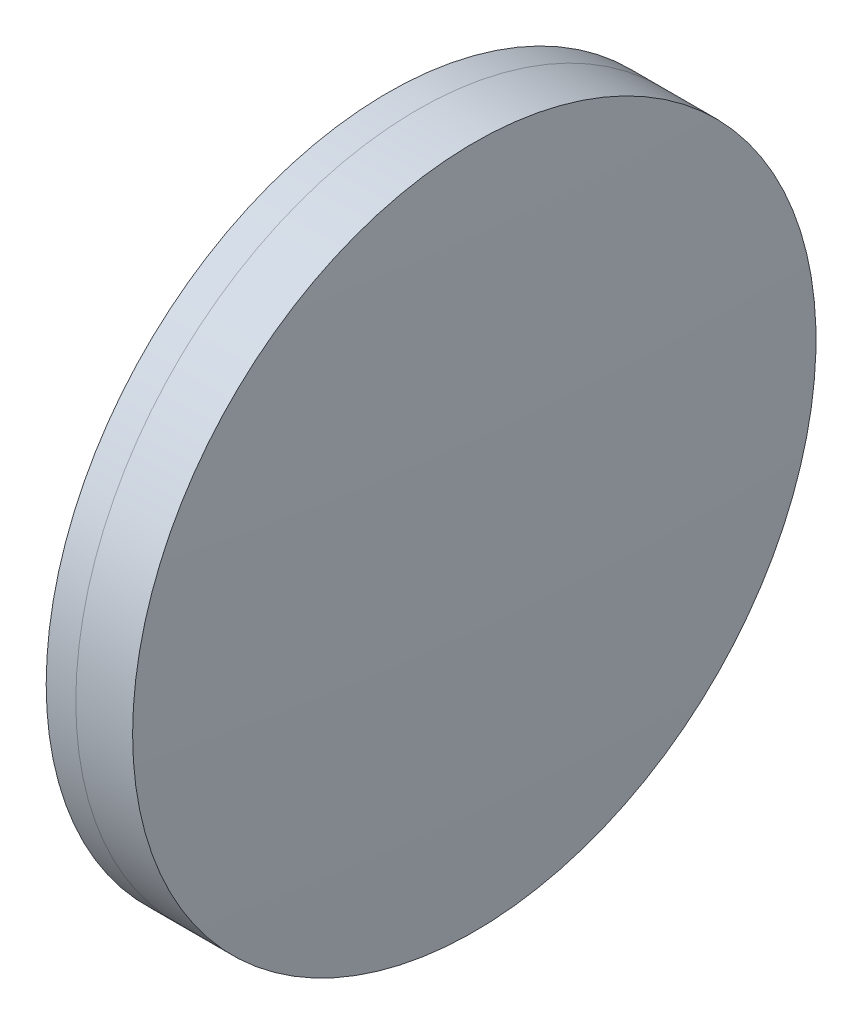
from build123d import *


with BuildPart() as part:
    # 草图1 one side → 旋转1 (revolve)
    with BuildSketch(Plane(origin=(0, 0, 0), x_dir=(1, 0, 0), z_dir=(0, 1, 0)), mode=Mode.PRIVATE) as revolve_1_sk:
        with BuildLine():
            ThreePointArc((364.195207485, 25.4), (362.416428287, 12.755323853), (361.821782443, 0))
            Line((361.821782443, 0), (369.321782443, 0))
            ThreePointArc((369.321782443, 0), (368.58781001, 12.784002736), (366.395538469, 25.4))
            Line((366.395538469, 25.4), (364.195207485, 25.4))
        make_face()
    revolve(revolve_1_sk.sketch.rotate(Axis((124.523309526, 0, 0), (1, 0, 0)), 180), axis=Axis((124.523309526, 0, 0), (1, 0, 0)))  # turned: the seam where the file's is


with BuildPart() as body_2:
    # 草图2 one side → 旋转3 (revolve)
    with BuildSketch(Plane(origin=(0, 0, 0), x_dir=(1, 0, 0), z_dir=(0, 1, 0)), mode=Mode.PRIVATE) as revolve_3_sk:
        with BuildLine():
            Line((370.618761713, 25.4), (366.395538469, 25.4))
            ThreePointArc((366.395538469, 25.4), (368.58781001, 12.784002736), (369.321782443, 0))
            Line((369.321782443, 0), (371.321782443, 0))
            ThreePointArc((371.321782443, 0), (371.145993613, 12.704863617), (370.618761713, 25.4))
        make_face()
    revolve(revolve_3_sk.sketch.rotate(Axis((-0.551919993, 0, 0), (1, 0, 0)), 180), axis=Axis((-0.551919993, 0, 0), (1, 0, 0)))  # turned: the seam where the file's is


solid = Compound([part.part, body_2.part])
